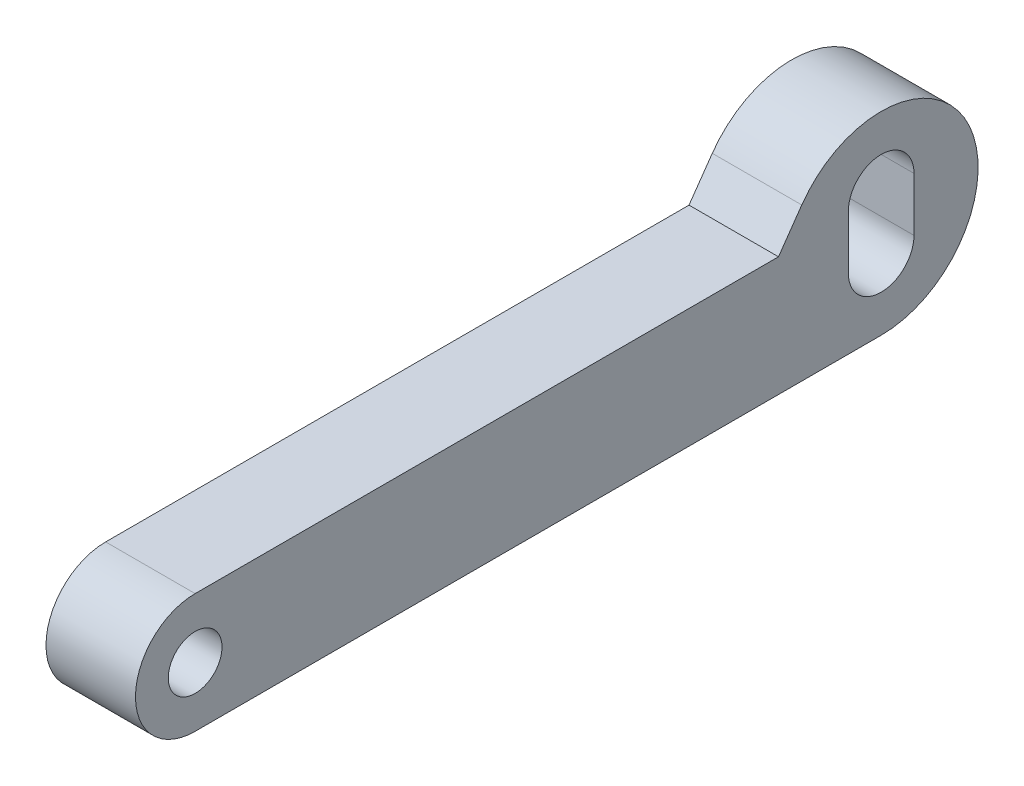
from build123d import *

# Parameters (mm, degrees)
SKETCH1_R      = 0.9
EXTRUDE1_DEPTH = 3


with BuildPart() as part:
    # Sketch1 → Extrude1 (new body)
    with BuildSketch(Plane(origin=(0, 0, 0), x_dir=(0, 0, -1), z_dir=(1, 0, 0))):
        with BuildLine():
            Line((0, 0), (23, 0))
            ThreePointArc((23, 0), (25.882785208, 4.750682993), (20.337755856, 5.114123418))
            Line((20.337755856, 5.114123418), (19.55763824, 4))
            Line((19.55763824, 4), (0, 4))
            ThreePointArc((0, 4), (-2, 2), (0, 0))
        make_face()
        with Locations((0, 2)):
            Circle(SKETCH1_R, mode=Mode.SUBTRACT)
        with BuildLine():
            Line((24.1, 4.15), (24.1, 2.35))
            ThreePointArc((24.1, 2.35), (23, 1.25), (21.9, 2.35))
            Line((21.9, 2.35), (21.9, 4.15))
            ThreePointArc((21.9, 4.15), (23, 5.25), (24.1, 4.15))
        make_face(mode=Mode.SUBTRACT)
    extrude(amount=EXTRUDE1_DEPTH)


solid = part.part
